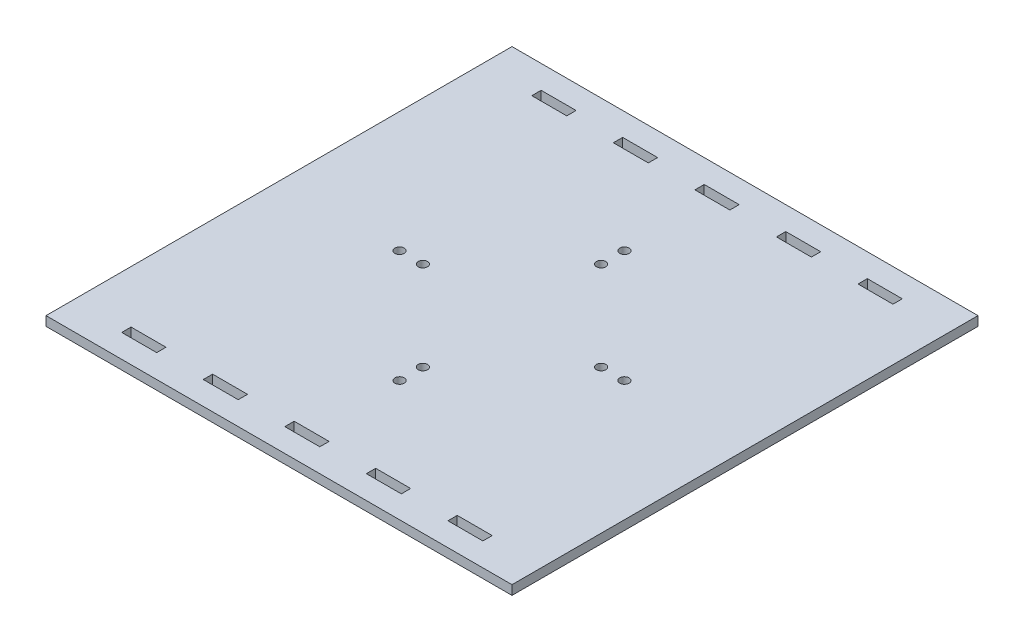
from build123d import *

# Parameters (mm, degrees)
SKETCH1_W           = 200
SKETCH1_H           = 200
SKETCH1_R           = 2
SKETCH1_W_2         = 15
SKETCH1_H_2         = 4
BOSS_EXTRUDE1_DEPTH = 4


with BuildPart() as part:
    # Sketch1 → Boss-Extrude1 (new body)
    with BuildSketch(Plane(origin=(0, 0, 0), x_dir=(1, 0, 0), z_dir=(0, 1, 0))):
        with Locations((100, -100)):
            Rectangle(SKETCH1_W, SKETCH1_H)
        with Locations((100, -61.75)):
            Circle(SKETCH1_R, mode=Mode.SUBTRACT)
        with Locations((100, -51.75)):
            Circle(SKETCH1_R, mode=Mode.SUBTRACT)
        with Locations((100, -148.25)):
            Circle(SKETCH1_R, mode=Mode.SUBTRACT)
        with Locations((100, -138.25)):
            Circle(SKETCH1_R, mode=Mode.SUBTRACT)
        with Locations((61.75, -100)):
            Circle(SKETCH1_R, mode=Mode.SUBTRACT)
        with Locations((51.75, -100)):
            Circle(SKETCH1_R, mode=Mode.SUBTRACT)
        with Locations((138.25, -100)):
            Circle(SKETCH1_R, mode=Mode.SUBTRACT)
        with Locations((148.25, -100)):
            Circle(SKETCH1_R, mode=Mode.SUBTRACT)
        with Locations((30, -12)):
            Rectangle(SKETCH1_W_2, SKETCH1_H_2, mode=Mode.SUBTRACT)
        with Locations((65, -12)):
            Rectangle(SKETCH1_W_2, SKETCH1_H_2, mode=Mode.SUBTRACT)
        with Locations((100, -12)):
            Rectangle(SKETCH1_W_2, SKETCH1_H_2, mode=Mode.SUBTRACT)
        with Locations((135, -12)):
            Rectangle(SKETCH1_W_2, SKETCH1_H_2, mode=Mode.SUBTRACT)
        with Locations((170, -12)):
            Rectangle(SKETCH1_W_2, SKETCH1_H_2, mode=Mode.SUBTRACT)
        with Locations((170, -188)):
            Rectangle(SKETCH1_W_2, SKETCH1_H_2, mode=Mode.SUBTRACT)
        with Locations((135, -188)):
            Rectangle(SKETCH1_W_2, SKETCH1_H_2, mode=Mode.SUBTRACT)
        with Locations((100, -188)):
            Rectangle(SKETCH1_W_2, SKETCH1_H_2, mode=Mode.SUBTRACT)
        with Locations((65, -188)):
            Rectangle(SKETCH1_W_2, SKETCH1_H_2, mode=Mode.SUBTRACT)
        with Locations((30, -188)):
            Rectangle(SKETCH1_W_2, SKETCH1_H_2, mode=Mode.SUBTRACT)
    extrude(amount=BOSS_EXTRUDE1_DEPTH)


solid = part.part
